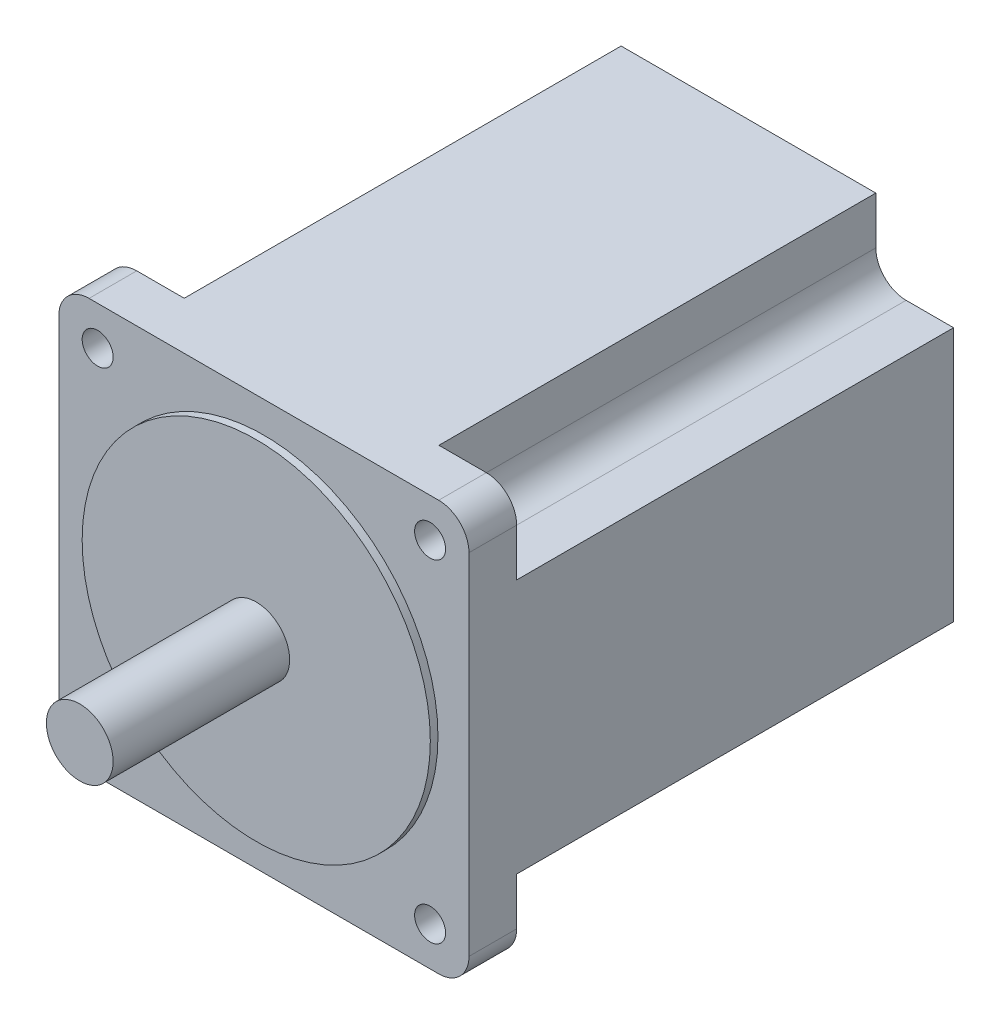
from build123d import *

# Parameters (mm, degrees)
SKETCH1_W           = 86
SKETCH1_H           = 86
BOSS_EXTRUDE1_DEPTH = 101.6
SKETCH2_R           = 36.5
BOSS_EXTRUDE2_DEPTH = 1.6
SKETCH3_R           = 7
BOSS_EXTRUDE3_DEPTH = 37
SKETCH5_R           = 3.25
CUT_EXTRUDE1_DEPTH  = 102.6
SKETCH4_W           = 16.3
SKETCH4_H           = 16.3
CUT_EXTRUDE2_DEPTH  = 91.6
FILLET1_R           = 6.35


with BuildPart() as part:
    # Sketch1 → Boss-Extrude1 (new body)
    with BuildSketch(Plane.XY):
        Rectangle(SKETCH1_W, SKETCH1_H)
    extrude(amount=-BOSS_EXTRUDE1_DEPTH)

    # Sketch2 → Boss-Extrude2 (add)
    with BuildSketch(Plane.XY):
        Circle(SKETCH2_R)
    extrude(amount=BOSS_EXTRUDE2_DEPTH)

    # Sketch3 → Boss-Extrude3 (add)
    with BuildSketch(Plane.XY.offset(1.6)):
        Circle(SKETCH3_R)
    extrude(amount=BOSS_EXTRUDE3_DEPTH)

    # Sketch5 → Cut-Extrude1 (cut, through all)
    with BuildSketch(Plane.XY):
        with Locations((-34.85, 34.85)):
            Circle(SKETCH5_R)
        with Locations((34.85, 34.85)):
            Circle(SKETCH5_R)
        with Locations((34.85, -34.85)):
            Circle(SKETCH5_R)
        with Locations((-34.85, -34.85)):
            Circle(SKETCH5_R)
    extrude(amount=-CUT_EXTRUDE1_DEPTH, mode=Mode.SUBTRACT)

    # Sketch4 → Cut-Extrude2 (cut)
    with BuildSketch(Plane(origin=(0, 0, -101.6), x_dir=(-1, 0, 0), z_dir=(0, 0, -1))):
        with Locations((-34.85, 34.85)):
            Rectangle(SKETCH4_W, SKETCH4_H)
        with Locations((-34.85, -34.85)):
            Rectangle(SKETCH4_W, SKETCH4_H)
        with Locations((34.85, -34.85)):
            Rectangle(SKETCH4_W, SKETCH4_H)
        with Locations((34.85, 34.85)):
            Rectangle(SKETCH4_W, SKETCH4_H)
    extrude(amount=-CUT_EXTRUDE2_DEPTH, mode=Mode.SUBTRACT)

    # Fillet1
    fillet1_edges = [part.edges().sort_by_distance(p)[0] for p in [
        (43, 43, -5),
        (-43, 43, -5),
        (-43, -43, -5),
        (43, -43, -5),
        (-26.7, 26.7, -55.8),
        (-26.7, -26.7, -55.8),
        (26.7, -26.7, -55.8),
        (26.7, 26.7, -55.8),
    ]]
    fillet(fillet1_edges, radius=FILLET1_R)


solid = part.part
